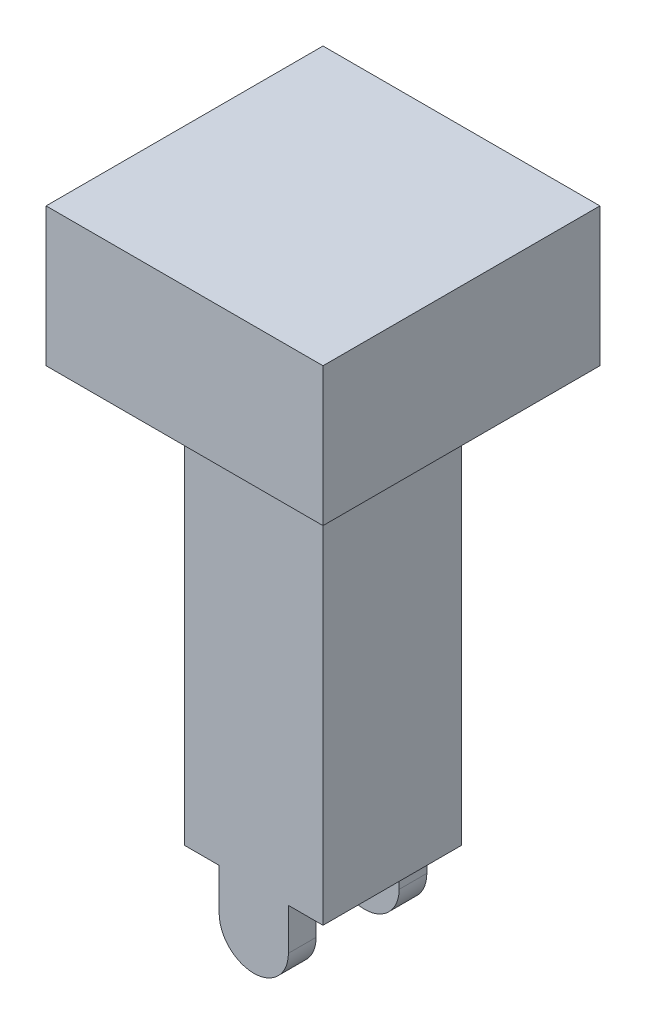
from build123d import *

# Parameters (mm, degrees)
SKETCH1_W           = 20
SKETCH1_H           = 20
BOSS_EXTRUDE1_DEPTH = 10
SKETCH2_W           = 10
SKETCH2_H           = 10
BOSS_EXTRUDE2_DEPTH = 30
SKETCH3_W           = 5
SKETCH3_H           = 2
BOSS_EXTRUDE3_DEPTH = 3
SKETCH4_R           = 2.5
BOSS_EXTRUDE4_DEPTH = 2


with BuildPart() as part:
    # Sketch1 → Boss-Extrude1 (new body)
    with BuildSketch(Plane(origin=(0, 0, 0), x_dir=(1, 0, 0), z_dir=(0, 1, 0))):
        Rectangle(SKETCH1_W, SKETCH1_H)
    extrude(amount=BOSS_EXTRUDE1_DEPTH)

    # Sketch2 → Boss-Extrude2 (add)
    with BuildSketch(Plane(origin=(0, 0, 0), x_dir=(-1, 0, 0), z_dir=(0, -1, 0))):
        Rectangle(SKETCH2_W, SKETCH2_H)
    extrude(amount=BOSS_EXTRUDE2_DEPTH)

    # Sketch3 → Boss-Extrude3 (add)
    with BuildSketch(Plane(origin=(0, -30, 0), x_dir=(-1, 0, 0), z_dir=(0, -1, 0))):
        with Locations((0, 4)):
            Rectangle(SKETCH3_W, SKETCH3_H)
        with Locations((0, -4)):
            Rectangle(SKETCH3_W, SKETCH3_H)
    extrude(amount=BOSS_EXTRUDE3_DEPTH)

    # Sketch4 → Boss-Extrude4 (add)
    with BuildSketch(Plane(origin=(0, 0, -5), x_dir=(1, 0, 0), z_dir=(0, 0, -1))):
        with Locations((0, 33)):
            Circle(SKETCH4_R)
    boss_extrude4 = extrude(amount=-BOSS_EXTRUDE4_DEPTH)

    # Mirror2: Boss-Extrude4 across plane
    add(boss_extrude4.mirror(Plane.XY))


solid = part.part
